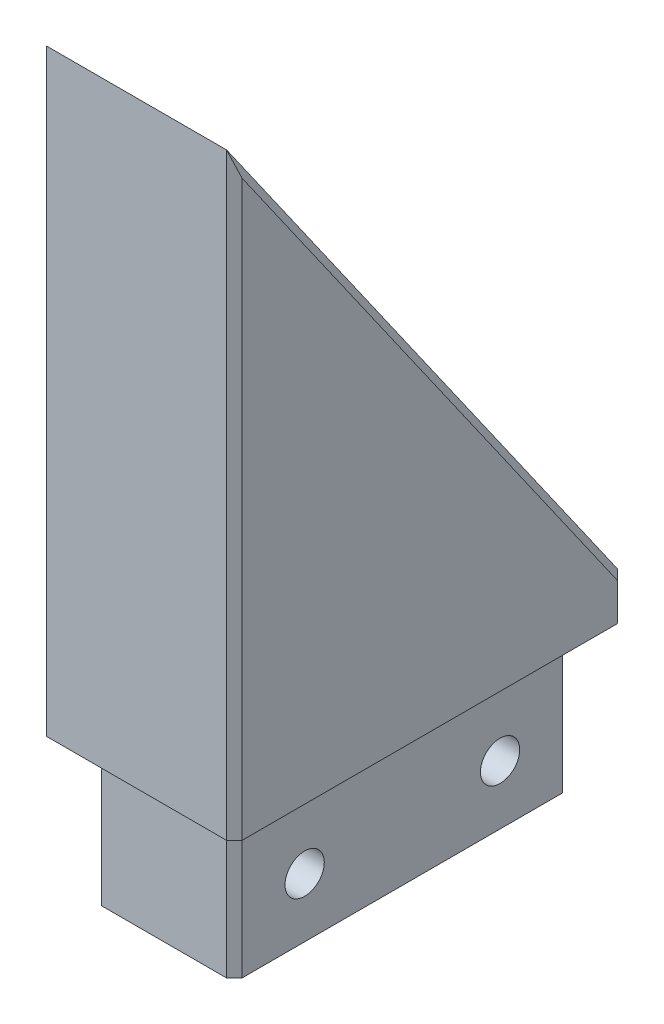
from build123d import *

# Parameters (mm, degrees)
BOSS_EXTRUDE1_DEPTH = 12.7
SKETCH2_W           = 18.288
SKETCH2_H           = 43.688
BOSS_EXTRUDE2_DEPTH = 19.05
SKETCH3_R           = 2.5527
CUT_EXTRUDE1_DEPTH  = 22.844
CHAMFER1_SIZE       = 1


with BuildPart() as part:
    # Sketch1 → Boss-Extrude1 (new body, symmetric)
    with BuildSketch(Plane(origin=(0, 0, 0), x_dir=(0, 0, -1), z_dir=(1, 0, 0))):
        Polygon((0, 0), (0, 77.724), (50.8, 5.174081258), (50.8, 0), align=None)
    extrude(amount=BOSS_EXTRUDE1_DEPTH, both=True)

    # Sketch2 → Boss-Extrude2 (add)
    with BuildSketch(Plane.XZ):
        with Locations((0, -25.4)):
            Rectangle(SKETCH2_W, SKETCH2_H)
    extrude(amount=BOSS_EXTRUDE2_DEPTH)

    # Sketch3 → Cut-Extrude1 (cut, through all)
    with BuildSketch(Plane(origin=(9.144, 0, 0), x_dir=(0, 0, -1), z_dir=(1, 0, 0))):
        with Locations((38.1, -11.375365521)):
            Circle(SKETCH3_R)
        with Locations((12.7, -11.375365521)):
            Circle(SKETCH3_R)
    extrude(amount=-CUT_EXTRUDE1_DEPTH, mode=Mode.SUBTRACT)

    # Chamfer1
    chamfer1_edges = [part.edges().sort_by_distance(p)[0] for p in [
        (12.7, 41.449040629, -25.4),
        (9.144, -9.525, -47.244),
        (9.144, -9.525, -3.556),
        (-9.144, -9.525, -3.556),
        (12.7, 38.862, 0),
        (-9.144, -9.525, -47.244),
        (-12.7, 38.862, 0),
        (-12.7, 41.449040629, -25.4),
        (-12.7, 2.587040629, -50.8),
        (12.7, 2.587040629, -50.8),
    ]]
    chamfer(chamfer1_edges, length=CHAMFER1_SIZE)


solid = part.part
